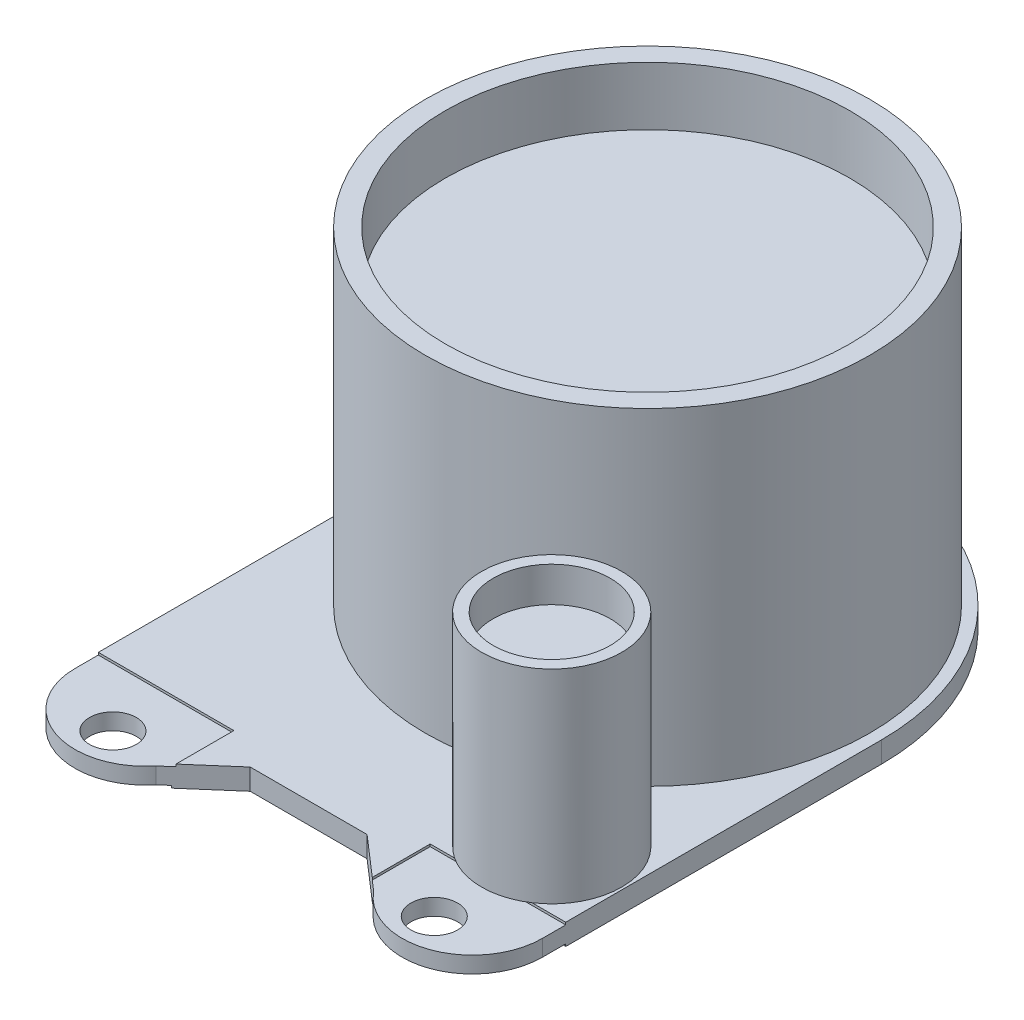
from build123d import *

# Parameters (mm, degrees)
ESQUISSE1_R             = 1
BOSS_EXTRU_1_DEPTH      = 0.9
ESQUISSE2_R             = 9.5
BOSS_EXTRU_2_DEPTH      = 14
ESQUISSE3_R             = 8.65
ENL_V_MAT_EXTRU_1_DEPTH = 2.5
ESQUISSE5_R             = 3
BOSS_EXTRU_3_DEPTH      = 8.7
ESQUISSE6_R             = 2.5
ENL_V_MAT_EXTRU_2_DEPTH = 1.5
ESQUISSE7_R             = 4.25
ESQUISSE7_W             = 5.7
ESQUISSE7_H             = 5
ENL_V_MAT_EXTRU_3_DEPTH = 0.1
ESQUISSE8_W             = 5.8
ESQUISSE8_H             = 5
ENL_V_MAT_EXTRU_4_DEPTH = 0.1


with BuildPart() as part:
    # Esquisse1 → Boss.-Extru.1 (new body)
    with BuildSketch(Plane(origin=(0, 0, 0), x_dir=(1, 0, 0), z_dir=(0, 1, 0))):
        with BuildLine():
            Line((-10, 0), (-10, -14.5))
            ThreePointArc((-10, -14.5), (-7.995629382, -17.329968575), (-4.66085191, -16.378399908))
            Line((-4.66085191, -16.378399908), (-2.5, -14.5))
            Line((-2.5, -14.5), (2.5, -14.5))
            Line((2.5, -14.5), (4.66085191, -16.378399908))
            ThreePointArc((4.66085191, -16.378399908), (7.995629382, -17.329968575), (10, -14.5))
            Line((10, -14.5), (10, 0))
            ThreePointArc((10, 0), (0, 10), (-10, 0))
        make_face()
        with Locations(Location((-6.875, -16, 0), (0, 0, 270))):  # turned: the seam where the file's is
            Circle(ESQUISSE1_R, mode=Mode.SUBTRACT)
        with Locations(Location((6.875, -16, 0), (0, 0, 270))):  # turned: the seam where the file's is
            Circle(ESQUISSE1_R, mode=Mode.SUBTRACT)
    extrude(amount=BOSS_EXTRU_1_DEPTH)

    # Esquisse2 → Boss.-Extru.2 (add)
    with BuildSketch(Plane(origin=(0, 0.9, 0), x_dir=(1, 0, 0), z_dir=(0, 1, 0))):
        with Locations(Location((0, 0, 0), (0, 0, 270))):  # turned: the seam where the file's is
            Circle(ESQUISSE2_R)
    extrude(amount=BOSS_EXTRU_2_DEPTH)

    # Esquisse3 → Enlèv. mat.-Extru.1 (cut)
    with BuildSketch(Plane(origin=(0, 14.9, 0), x_dir=(1, 0, 0), z_dir=(0, 1, 0))):
        with Locations(Location((0, 0, 0), (0, 0, 270))):  # turned: the seam where the file's is
            Circle(ESQUISSE3_R)
    extrude(amount=-ENL_V_MAT_EXTRU_1_DEPTH, mode=Mode.SUBTRACT)

    # Esquisse5 → Boss.-Extru.3 (add)
    with BuildSketch(Plane(origin=(0, 0.9, 0), x_dir=(1, 0, 0), z_dir=(0, 1, 0))):
        with Locations(Location((6.9, -11, 0), (0, 0, 90))):  # turned: the seam where the file's is
            Circle(ESQUISSE5_R)
    extrude(amount=BOSS_EXTRU_3_DEPTH)

    # Esquisse6 → Enlèv. mat.-Extru.2 (cut)
    with BuildSketch(Plane(origin=(0, 9.6, 0), x_dir=(1, 0, 0), z_dir=(0, 1, 0))):
        with Locations(Location((6.9, -11, 0), (0, 0, 270))):  # turned: the seam where the file's is
            Circle(ESQUISSE6_R)
    extrude(amount=-ENL_V_MAT_EXTRU_2_DEPTH, mode=Mode.SUBTRACT)

    # Esquisse7 → Enlèv. mat.-Extru.3 (cut)
    with BuildSketch(Plane.XZ):
        with Locations(Location((0, 0, 0), (0, 0, 270))):  # turned: the seam where the file's is
            Circle(ESQUISSE7_R)
        with Locations((-7.15, 16)):
            Rectangle(ESQUISSE7_W, ESQUISSE7_H)
        with Locations((7.15, 16)):
            Rectangle(ESQUISSE7_W, ESQUISSE7_H)
    extrude(amount=-ENL_V_MAT_EXTRU_3_DEPTH, mode=Mode.SUBTRACT)

    # Esquisse8 → Enlèv. mat.-Extru.4 (cut)
    with BuildSketch(Plane(origin=(0, 0.9, 0), x_dir=(1, 0, 0), z_dir=(0, 1, 0))):
        with Locations((-7.1, -16)):
            Rectangle(ESQUISSE8_W, ESQUISSE8_H)
        with Locations((7.1, -16)):
            Rectangle(ESQUISSE8_W, ESQUISSE8_H)
    extrude(amount=-ENL_V_MAT_EXTRU_4_DEPTH, mode=Mode.SUBTRACT)


solid = part.part
